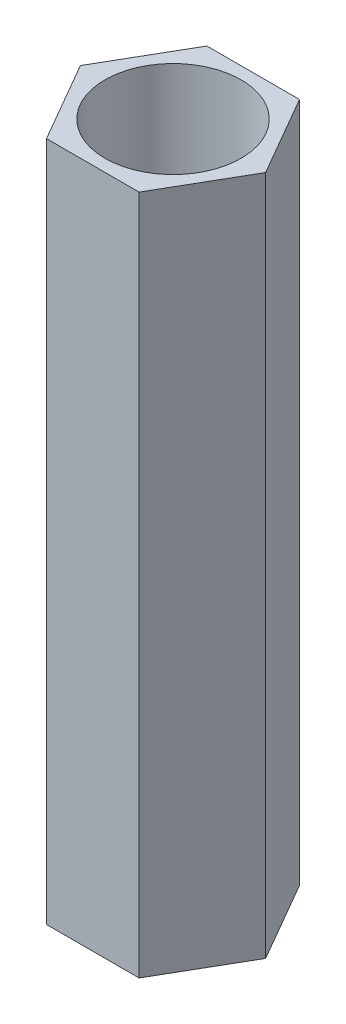
from build123d import *

# Parameters (mm, degrees)
SKETCH1_R           = 1.4
BOSS_EXTRUDE1_DEPTH = 14


with BuildPart() as part:
    # Sketch1 → Boss-Extrude1 (new body)
    with BuildSketch(Plane(origin=(0, 0, 0), x_dir=(1, 0, 0), z_dir=(0, 1, 0))):
        Polygon((1.905255888, 0), (0.952627944, 1.65), (-0.952627944, 1.65), (-1.905255888, 0), (-0.952627944, -1.65), (0.952627944, -1.65), align=None)
        Circle(SKETCH1_R, mode=Mode.SUBTRACT)
    extrude(amount=BOSS_EXTRUDE1_DEPTH)


solid = part.part
